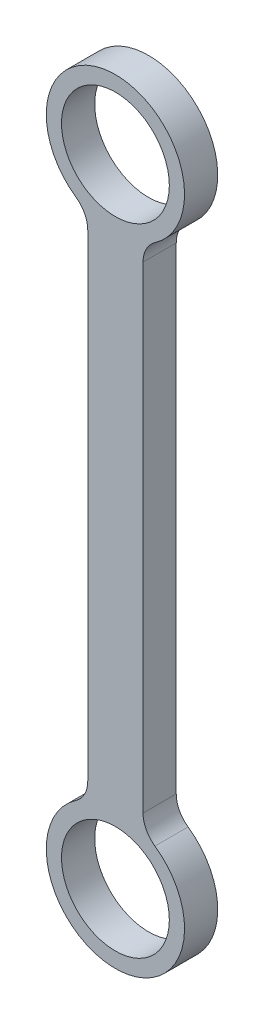
from build123d import *

# Parameters (mm, degrees)
SALIENTE_EXTRUIR1_DEPTH = 6
REDONDEO1_R             = 5


with BuildPart() as part:
    # Croquis1 → Saliente-Extruir1 (new body)
    with BuildSketch(Plane.XY):
        with BuildLine():
            ThreePointArc((-5, 103.543560763), (0, 102.5), (5, 103.543560763))
            Line((5, 103.543560763), (5, 106.629665479))
            ThreePointArc((5, 106.629665479), (0, 105.25), (-5, 106.629665479))
            Line((-5, 106.629665479), (-5, 103.543560763))
        make_face()
        with BuildLine():
            Line((5, 106.629665479), (5, 103.543560763))
            ThreePointArc((5, 103.543560763), (10.458250332, 108.153468031), (12.5, 115))
            ThreePointArc((12.5, 115), (-6.846531969, 125.458250332), (-5, 103.543560763))
            Line((-5, 103.543560763), (-5, 106.629665479))
            ThreePointArc((-5, 106.629665479), (-4.812094139, 123.479755303), (9.75, 115))
            ThreePointArc((9.75, 115), (8.479755303, 110.187905861), (5, 106.629665479))
        make_face()
        with BuildLine():
            ThreePointArc((-5, 11.456439237), (0, 12.5), (5, 11.456439237))
            Line((5, 11.456439237), (5, 103.543560763))
            ThreePointArc((5, 103.543560763), (0, 102.5), (-5, 103.543560763))
            Line((-5, 103.543560763), (-5, 11.456439237))
        make_face()
        with BuildLine():
            ThreePointArc((-5, 8.370334521), (0, 9.75), (5, 8.370334521))
            Line((5, 8.370334521), (5, 11.456439237))
            ThreePointArc((5, 11.456439237), (0, 12.5), (-5, 11.456439237))
            Line((-5, 11.456439237), (-5, 8.370334521))
        make_face()
        with BuildLine():
            Line((5, 11.456439237), (5, 8.370334521))
            ThreePointArc((5, 8.370334521), (8.479755303, 4.812094139), (9.75, 0))
            ThreePointArc((9.75, 0), (-4.812094139, -8.479755303), (-5, 8.370334521))
            Line((-5, 8.370334521), (-5, 11.456439237))
            ThreePointArc((-5, 11.456439237), (-6.846531969, -10.458250332), (12.5, 0))
            ThreePointArc((12.5, 0), (10.458250332, 6.846531969), (5, 11.456439237))
        make_face()
    extrude(amount=SALIENTE_EXTRUIR1_DEPTH)

    # Redondeo1
    redondeo1_edges = [part.edges().sort_by_distance(p)[0] for p in [
        (-5, 11.456439237, 3),
        (-5, 103.543560763, 3),
        (5, 103.543560763, 3),
        (5, 11.456439237, 3),
    ]]
    fillet(redondeo1_edges, radius=REDONDEO1_R)


solid = part.part
